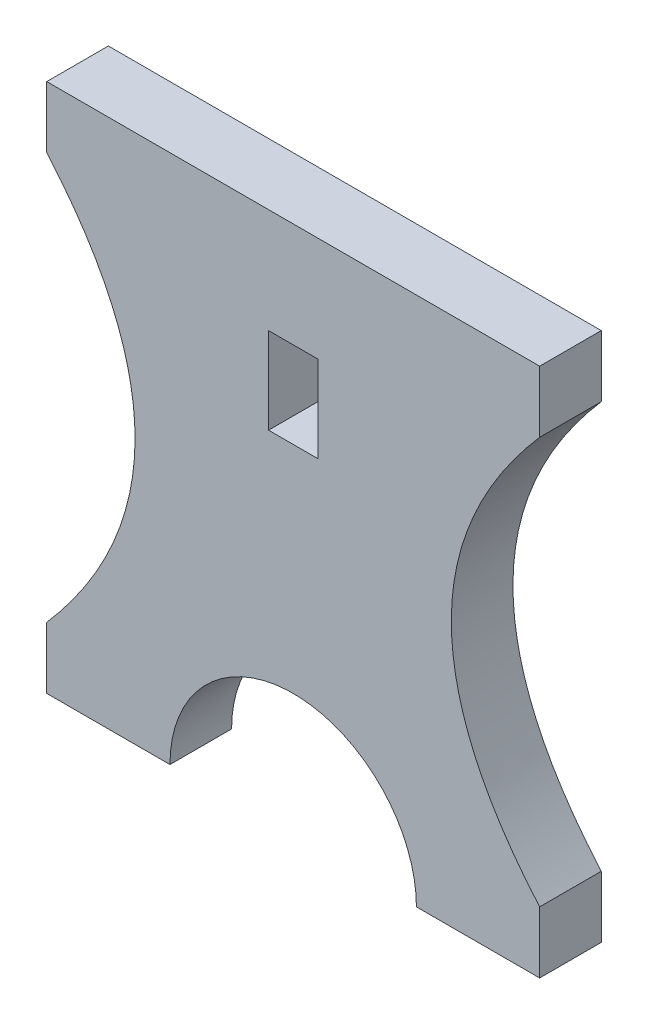
from build123d import *

# Parameters (mm, degrees)
SKETCH_1_W      = 40
SKETCH_1_H      = 70
EXTRUDE_3_DEPTH = 50


with BuildPart() as part:
    # Эскиз1 → Бобышка-Вытянуть3 (new body)
    with BuildSketch(Plane.XY):
        with BuildLine():
            Line((-100, -215), (-200, -215))
            Line((-200, -215), (-200, -165))
            add(Edge.make_bspline(
                [(-200, 165), (-56.658015908, 0), (-200, -165)],
                knots=[0, 0, 0, 1, 1, 1], degree=2))
            Line((-200, 165), (-200, 215))
            Line((-200, 215), (0, 215))
            Line((0, 215), (200, 215))
            Line((200, 215), (200, 165))
            add(Edge.make_bspline(
                [(200, 165), (56.658015908, 0), (200, -165)],
                knots=[0, 0, 0, 1, 1, 1], degree=2))
            Line((200, -165), (200, -215))
            Line((200, -215), (100, -215))
            ThreePointArc((100, -215), (0, -115), (-100, -215))
        make_face()
        with Locations((0, 95)):
            Rectangle(SKETCH_1_W, SKETCH_1_H, mode=Mode.SUBTRACT)
    extrude(amount=EXTRUDE_3_DEPTH)


solid = part.part
